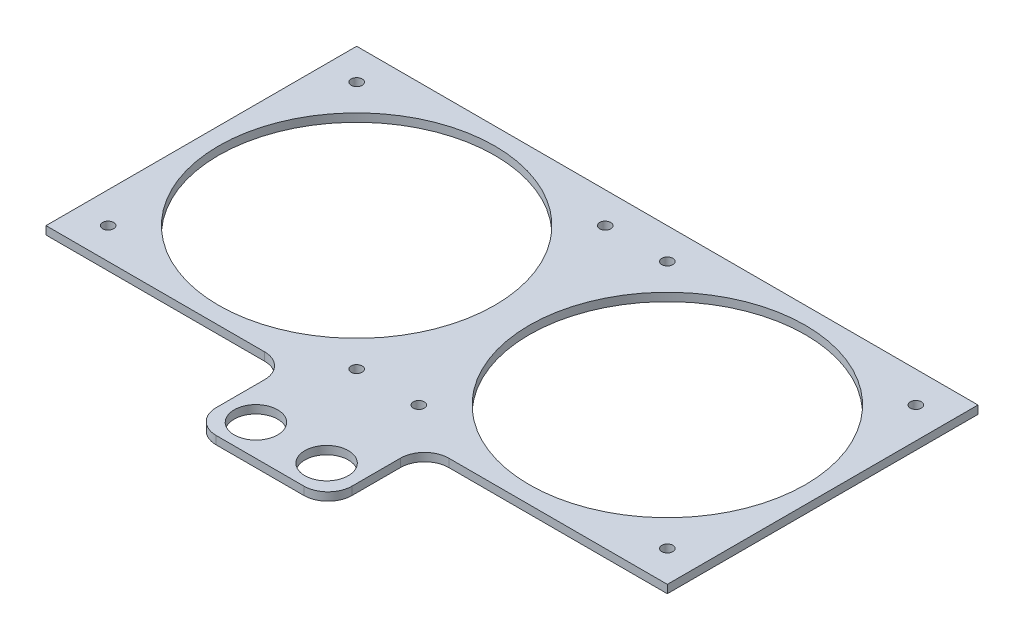
from build123d import *

# Parameters (mm, degrees)
SKETCH1_W           = 114.3
SKETCH1_H           = 114.3
SKETCH1_R           = 50.8
SKETCH1_R_2         = 2.032
BOSS_EXTRUDE1_DEPTH = 3
SKETCH3_W           = 50
SKETCH3_H           = 3
BOSS_EXTRUDE2_DEPTH = 35.56
SKETCH4_R           = 8
CUT_EXTRUDE1_DEPTH  = 4
FILLET2_R           = 8.89


with BuildPart() as part:
    # Sketch1 → Boss-Extrude1 (new body)
    with BuildSketch(Plane(origin=(0, 0, 0), x_dir=(1, 0, 0), z_dir=(0, 1, 0))):
        with Locations((57.15, 57.15)):
            Rectangle(SKETCH1_W, SKETCH1_H)
        with Locations((57.15, 57.15)):
            Circle(SKETCH1_R, mode=Mode.SUBTRACT)
        with Locations((11.43, 102.87)):
            Circle(SKETCH1_R_2, mode=Mode.SUBTRACT)
        with Locations((102.87, 102.87)):
            Circle(SKETCH1_R_2, mode=Mode.SUBTRACT)
        with Locations((102.87, 11.43)):
            Circle(SKETCH1_R_2, mode=Mode.SUBTRACT)
        with Locations((11.43, 11.43)):
            Circle(SKETCH1_R_2, mode=Mode.SUBTRACT)
    boss_extrude1 = extrude(amount=BOSS_EXTRUDE1_DEPTH)

    # Mirror1: Boss-Extrude1 across plane
    add(boss_extrude1.mirror(Plane(origin=(114.3, 3, 0), x_dir=(0, 0, 1), z_dir=(-1, 0, 0))))

    # Sketch3 → Boss-Extrude2 (add)
    with BuildSketch(Plane.XY):
        with Locations((114.3, 1.5)):
            Rectangle(SKETCH3_W, SKETCH3_H)
    extrude(amount=BOSS_EXTRUDE2_DEPTH)

    # Sketch4 → Cut-Extrude1 (cut, through all)
    with BuildSketch(Plane(origin=(0, 3, 0), x_dir=(1, 0, 0), z_dir=(0, 1, 0))):
        with Locations((101.3, -24.06)):
            Circle(SKETCH4_R)
        with Locations((127.3, -24.06)):
            Circle(SKETCH4_R)
    extrude(amount=-CUT_EXTRUDE1_DEPTH, mode=Mode.SUBTRACT)

    # Fillet2
    fillet2_edges = [part.edges().sort_by_distance(p)[0] for p in [
        (139.3, 1.5, 0),
        (89.3, 1.5, 0),
        (139.3, 1.5, 35.56),
        (89.3, 1.5, 35.56),
    ]]
    fillet(fillet2_edges, radius=FILLET2_R)


solid = part.part
